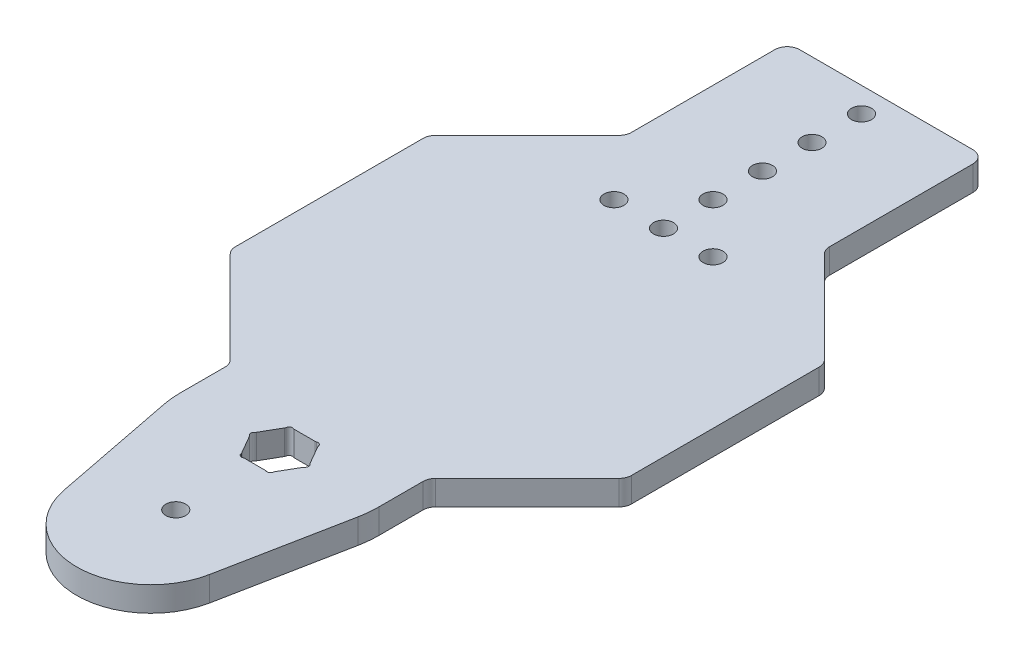
from build123d import *

# Parameters (mm, degrees)
SKETCH1_R           = 2.5527
BOSS_EXTRUDE1_DEPTH = 6.35


with BuildPart() as part:
    # Sketch1 → Boss-Extrude1 (new body)
    with BuildSketch(Plane.XZ):
        with BuildLine():
            Line((-50.8, 24.084871939), (-50.8, -24.084871939))
            ThreePointArc((-50.8, -24.084871939), (-50.558317516, -25.299891837), (-49.87006403, -26.32993597))
            Line((-49.87006403, -26.32993597), (-26.32993597, -49.87006403))
            ThreePointArc((-26.32993597, -49.87006403), (-25.641682484, -50.900108163), (-25.4, -52.115128061))
            Line((-25.4, -52.115128061), (-25.4, -88.9))
            ThreePointArc((-25.4, -88.9), (-24.47006403, -91.14506403), (-22.225, -92.075))
            Line((-22.225, -92.075), (22.225, -92.075))
            ThreePointArc((22.225, -92.075), (24.47006403, -91.14506403), (25.4, -88.9))
            Line((25.4, -88.9), (25.4, -52.115128061))
            ThreePointArc((25.4, -52.115128061), (25.641682484, -50.900108163), (26.32993597, -49.87006403))
            Line((26.32993597, -49.87006403), (49.87006403, -26.32993597))
            ThreePointArc((49.87006403, -26.32993597), (50.558317516, -25.299891837), (50.8, -24.084871939))
            Line((50.8, -24.084871939), (50.8, 24.084871939))
            ThreePointArc((50.8, 24.084871939), (50.558317516, 25.299891837), (49.87006403, 26.32993597))
            Line((49.87006403, 26.32993597), (26.32993597, 49.87006403))
            ThreePointArc((26.32993597, 49.87006403), (25.641682484, 50.900108163), (25.4, 52.115128061))
            Line((25.4, 52.115128061), (25.4, 63.5))
            ThreePointArc((25.4, 63.5), (25.281197373, 65.953784703), (24.925900837, 68.384615385))
            Line((24.925900837, 68.384615385), (18.694425628, 100.183461538))
            ThreePointArc((18.694425628, 100.183461538), (0, 115.57), (-18.694425628, 100.183461538))
            Line((-18.694425628, 100.183461538), (-24.925900837, 68.384615385))
            ThreePointArc((-24.925900837, 68.384615385), (-25.281197373, 65.953784703), (-25.4, 63.5))
            Line((-25.4, 63.5), (-25.4, 52.115128061))
            ThreePointArc((-25.4, 52.115128061), (-25.641682484, 50.900108163), (-26.32993597, 49.87006403))
            Line((-26.32993597, 49.87006403), (-49.87006403, 26.32993597))
            ThreePointArc((-49.87006403, 26.32993597), (-50.558317516, 25.299891837), (-50.8, 24.084871939))
        make_face()
        with Locations((0, 90.17)):
            Circle(SKETCH1_R, mode=Mode.SUBTRACT)
        with Locations((0, -85.725)):
            Circle(SKETCH1_R, mode=Mode.SUBTRACT)
        with Locations((0, -73.025)):
            Circle(SKETCH1_R, mode=Mode.SUBTRACT)
        with Locations((0, -60.325)):
            Circle(SKETCH1_R, mode=Mode.SUBTRACT)
        with Locations((0, -47.625)):
            Circle(SKETCH1_R, mode=Mode.SUBTRACT)
        with Locations((0, -34.925)):
            Circle(SKETCH1_R, mode=Mode.SUBTRACT)
        with Locations((-12.7, -34.925)):
            Circle(SKETCH1_R, mode=Mode.SUBTRACT)
        with Locations((12.7, -34.925)):
            Circle(SKETCH1_R, mode=Mode.SUBTRACT)
        with BuildLine():
            Line((-6.872513185, 64.423457988), (-4.235994669, 68.990042012))
            ThreePointArc((-4.235994669, 68.990042012), (-4.173607217, 69.126443703), (-4.137993663, 69.272146448))
            ThreePointArc((-4.137993663, 69.272146448), (-3.702835951, 69.9135), (-2.929828627, 69.969680857))
            ThreePointArc((-2.929828627, 69.969680857), (-2.785839571, 69.927671726), (-2.636518516, 69.9135))
            Line((-2.636518516, 69.9135), (2.636518516, 69.9135))
            ThreePointArc((2.636518516, 69.9135), (2.785839571, 69.927671726), (2.929828627, 69.969680857))
            ThreePointArc((2.929828627, 69.969680857), (3.702835951, 69.9135), (4.137993663, 69.272146448))
            ThreePointArc((4.137993663, 69.272146448), (4.173607217, 69.126443703), (4.235994669, 68.990042012))
            Line((4.235994669, 68.990042012), (6.872513185, 64.423457988))
            ThreePointArc((6.872513185, 64.423457988), (6.959446788, 64.301228024), (7.06782229, 64.197534409))
            ThreePointArc((7.06782229, 64.197534409), (7.405671903, 63.5), (7.06782229, 62.802465591))
            ThreePointArc((7.06782229, 62.802465591), (6.959446788, 62.698771976), (6.872513185, 62.576542012))
            Line((6.872513185, 62.576542012), (4.235994669, 58.009957988))
            ThreePointArc((4.235994669, 58.009957988), (4.173607217, 57.873556297), (4.137993663, 57.727853552))
            ThreePointArc((4.137993663, 57.727853552), (3.702835951, 57.0865), (2.929828627, 57.030319143))
            ThreePointArc((2.929828627, 57.030319143), (2.785839571, 57.072328274), (2.636518516, 57.0865))
            Line((2.636518516, 57.0865), (-2.636518516, 57.0865))
            ThreePointArc((-2.636518516, 57.0865), (-2.785839571, 57.072328274), (-2.929828627, 57.030319143))
            ThreePointArc((-2.929828627, 57.030319143), (-3.702835951, 57.0865), (-4.137993663, 57.727853552))
            ThreePointArc((-4.137993663, 57.727853552), (-4.173607217, 57.873556297), (-4.235994669, 58.009957988))
            Line((-4.235994669, 58.009957988), (-6.872513185, 62.576542012))
            ThreePointArc((-6.872513185, 62.576542012), (-6.959446788, 62.698771976), (-7.06782229, 62.802465591))
            ThreePointArc((-7.06782229, 62.802465591), (-7.405671903, 63.5), (-7.06782229, 64.197534409))
            ThreePointArc((-7.06782229, 64.197534409), (-6.959446788, 64.301228024), (-6.872513185, 64.423457988))
        make_face(mode=Mode.SUBTRACT)
    extrude(amount=-BOSS_EXTRUDE1_DEPTH)


solid = part.part
